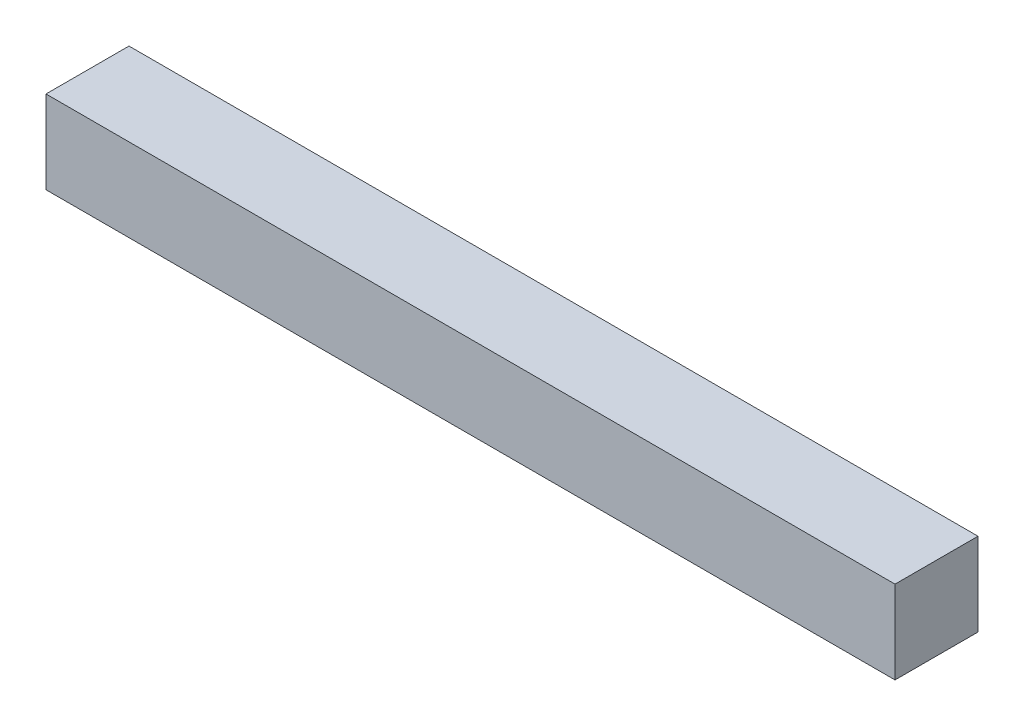
from build123d import *

# Parameters (mm, degrees)
ESQUISSE1_W        = 133
ESQUISSE1_H        = 13
BOSS_EXTRU_1_DEPTH = 13


with BuildPart() as part:
    # Esquisse1 → Boss.-Extru.1 (new body)
    with BuildSketch(Plane.XY):
        with Locations((-4.10685118, 33.672413793)):
            Rectangle(ESQUISSE1_W, ESQUISSE1_H)
    extrude(amount=BOSS_EXTRU_1_DEPTH)


solid = part.part
